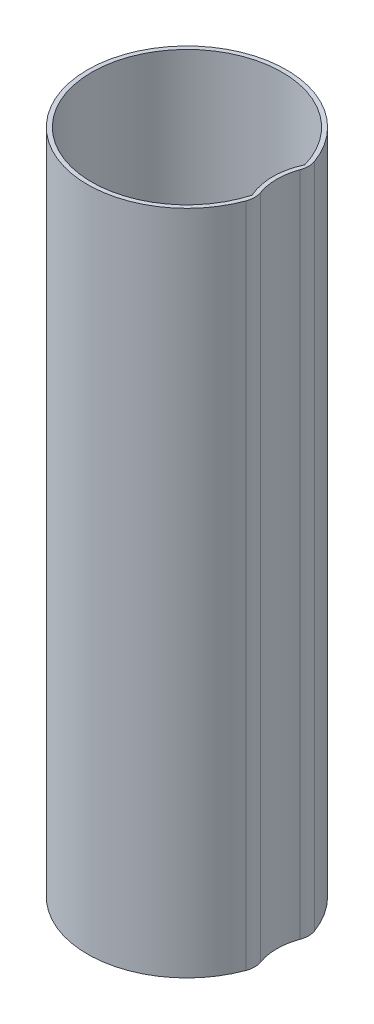
from build123d import *

# Parameters (mm, degrees)
BOSS_EXTRUDE1_DEPTH = 63
FILLET2_R           = 2


with BuildPart() as part:
    # Sketch1 → Boss-Extrude1 (new body)
    with BuildSketch(Plane(origin=(0, 0, 0), x_dir=(1, 0, 0), z_dir=(0, 1, 0))):
        with BuildLine():
            ThreePointArc((9.075357143, 2.44905956), (-9.4, 0), (9.075357143, -2.44905956))
            ThreePointArc((9.075357143, -2.44905956), (8.5, 0), (9.075357143, 2.44905956))
        make_face()
        with BuildLine():
            ThreePointArc((8.649642857, 2.486700312), (8.1, 0), (8.649642857, -2.486700312))
            ThreePointArc((8.649642857, -2.486700312), (-9, 0), (8.649642857, 2.486700312))
        make_face(mode=Mode.SUBTRACT)
    extrude(amount=BOSS_EXTRUDE1_DEPTH)

    # Fillet2
    fillet2_edges = [part.edges().sort_by_distance(p)[0] for p in [
        (9.075357143, 31.5, 2.44905956),
        (9.075357143, 31.5, -2.44905956),
    ]]
    fillet(fillet2_edges, radius=FILLET2_R)


solid = part.part
